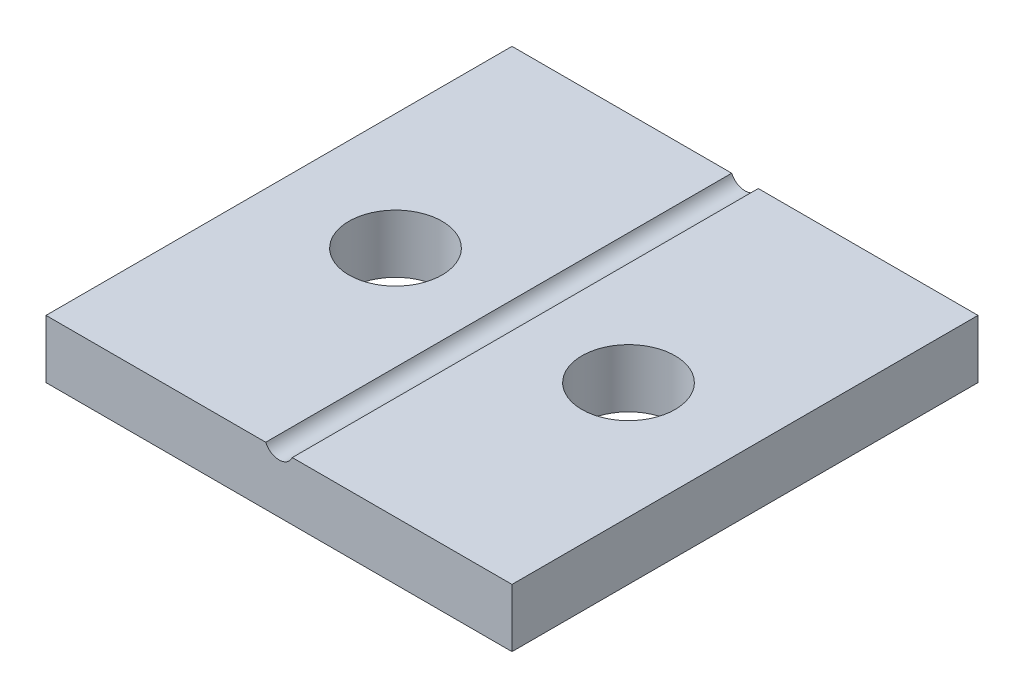
from build123d import *

# Parameters (mm, degrees)
SKETCH1_W           = 20
SKETCH1_H           = 20
BOSS_EXTRUDE1_DEPTH = 2.5
SKETCH2_R           = 0.6223
CUT_EXTRUDE1_DEPTH  = 21
SKETCH3_R           = 2
CUT_EXTRUDE2_DEPTH  = 3.5


with BuildPart() as part:
    # Sketch1 → Boss-Extrude1 (new body)
    with BuildSketch(Plane(origin=(0, 0, 0), x_dir=(1, 0, 0), z_dir=(0, 1, 0))):
        with Locations((-50.754716981, 42.075471698)):
            Rectangle(SKETCH1_W, SKETCH1_H)
    extrude(amount=BOSS_EXTRUDE1_DEPTH)

    # Sketch2 → Cut-Extrude1 (cut, through all)
    with BuildSketch(Plane.XY.offset(-32.075471698)):
        with Locations((-50.754716981, 2.75)):
            Circle(SKETCH2_R)
    extrude(amount=-CUT_EXTRUDE1_DEPTH, mode=Mode.SUBTRACT)

    # Sketch3 → Cut-Extrude2 (cut, through all)
    with BuildSketch(Plane(origin=(0, 2.5, 0), x_dir=(1, 0, 0), z_dir=(0, 1, 0))):
        with Locations((-55.754716981, 42.075471698)):
            Circle(SKETCH3_R)
        with Locations((-45.754716981, 42.075471698)):
            Circle(SKETCH3_R)
    extrude(amount=-CUT_EXTRUDE2_DEPTH, mode=Mode.SUBTRACT)


solid = part.part
